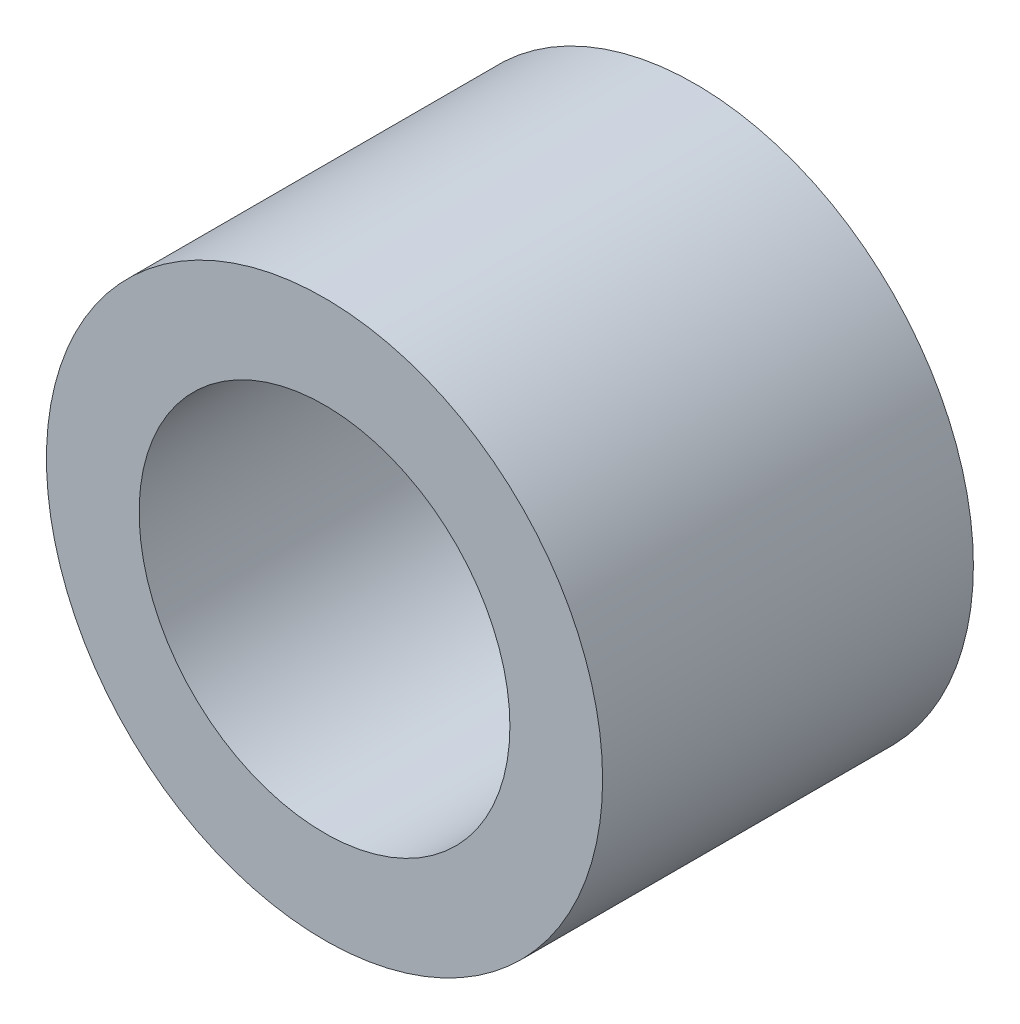
from build123d import *

# Parameters (mm, degrees)
SKETCH1_R           = 3
SKETCH1_R_2         = 2
BOSS_EXTRUDE1_DEPTH = 4


with BuildPart() as part:
    # Sketch1 → Boss-Extrude1 (new body)
    with BuildSketch(Plane.XY):
        Circle(SKETCH1_R)
        Circle(SKETCH1_R_2, mode=Mode.SUBTRACT)
    extrude(amount=BOSS_EXTRUDE1_DEPTH)


solid = part.part
